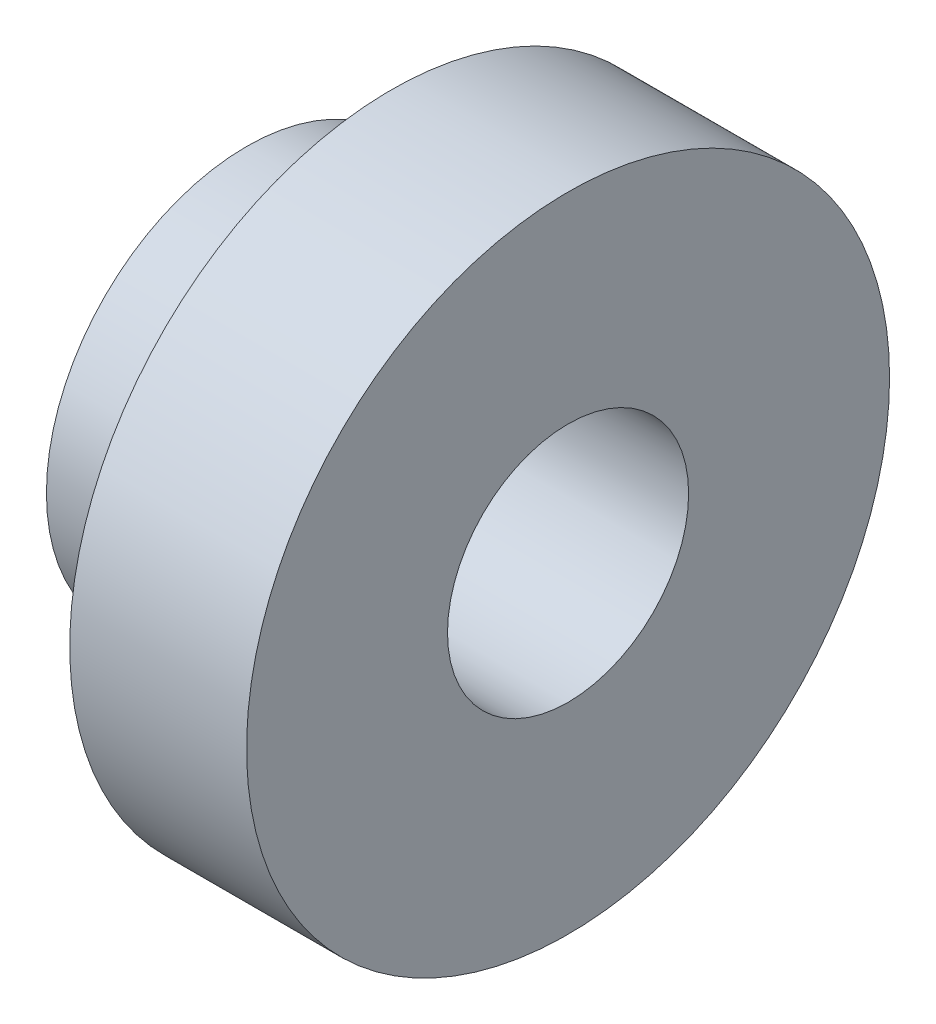
from build123d import *


with BuildPart() as part:
    # Esquisse1 → Révolution1 (revolve)
    with BuildSketch(Plane.XY, mode=Mode.PRIVATE) as r_volution1_sk:
        Polygon((0, 4), (0, 1.5), (-4, 1.5), (-4, 2.49), (-2.2, 2.49), (-2.2, 4), align=None)
    revolve(r_volution1_sk.sketch.rotate(Axis((0, 0, 0), (-1, 0, 0)), 90), axis=Axis((0, 0, 0), (-1, 0, 0)))  # turned: the seam where the file's is


solid = part.part
